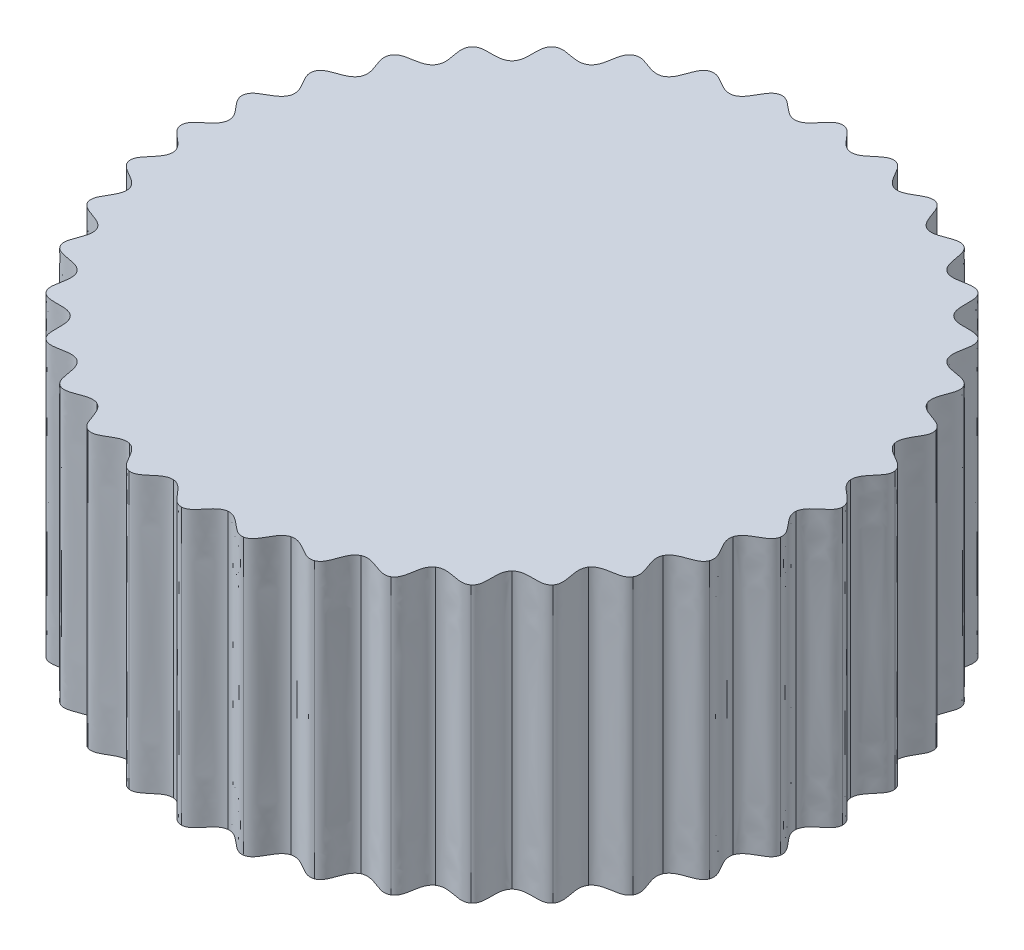
from build123d import *

# Parameters (mm, degrees)
BOSS_EXTRUDE1_DEPTH = 30


with BuildPart() as part:
    # Sketch1 → Boss-Extrude1 (new body)
    with BuildSketch(Plane(origin=(0, 0, 0), x_dir=(1, 0, 0), z_dir=(0, 1, 0))):
        with BuildLine():
            add(Edge.make_bspline(
                [(0, 36), (0.625233227, 36.007554002), (1.481885387, 34.899321986), (2.337586506, 33.935041496), (2.963295253, 33.870619735)],
                knots=[0, 0, 0, 0, 0.5, 1, 1, 1, 1], degree=3))
            add(Edge.make_bspline(
                [(6.251334396, 35.453079108), (5.636911605, 35.569088959), (4.600831447, 34.626449564), (3.590684801, 33.825409601), (2.963295253, 33.870619735)],
                knots=[0, 0, 0, 0, 0.5, 1, 1, 1, 1], degree=3))
            add(Edge.make_bspline(
                [(6.251334396, 35.453079108), (6.868380664, 35.351947738), (7.519575883, 34.11179617), (8.194831429, 33.013574328), (8.799847533, 32.841478094)],
                knots=[0, 0, 0, 0, 0.5, 1, 1, 1, 1], degree=3))
            add(Edge.make_bspline(
                [(12.31272516, 33.828934348), (11.727781731, 34.049875146), (10.543754345, 33.301469993), (9.409854966, 32.688009752), (8.799847533, 32.841478094)],
                knots=[0, 0, 0, 0, 0.5, 1, 1, 1, 1], degree=3))
            add(Edge.make_bspline(
                [(12.31272516, 33.828934348), (12.90283583, 33.62219043), (13.328787871, 32.287800688), (13.803080546, 31.089006408), (14.369020899, 30.814464759)],
                knots=[0, 0, 0, 0, 0.5, 1, 1, 1, 1], degree=3))
            add(Edge.make_bspline(
                [(18, 31.176914536), (17.462309143, 31.496073107), (16.166310602, 30.964642108), (14.943111451, 30.557401267), (14.369020899, 30.814464759)],
                knots=[0, 0, 0, 0, 0.5, 1, 1, 1, 1], degree=3))
            add(Edge.make_bspline(
                [(18, 31.176914536), (18.545244859, 30.87083988), (18.733011384, 29.482756721), (18.991930046, 28.219814761), (19.501598836, 27.851169506)],
                knots=[0, 0, 0, 0, 0.5, 1, 1, 1, 1], degree=3))
            add(Edge.make_bspline(
                [(23.140353949, 27.577599952), (22.666253128, 27.985278825), (21.297661693, 27.686969242), (20.022329055, 27.498321608), (19.501598836, 27.851169506)],
                knots=[0, 0, 0, 0, 0.5, 1, 1, 1, 1], degree=3))
            add(Edge.make_bspline(
                [(23.140353949, 27.577599952), (23.624166007, 27.181494482), (23.568041825, 25.78189411), (23.603719361, 24.493178323), (24.04163056, 24.04163056)],
                knots=[0, 0, 0, 0, 0.5, 1, 1, 1, 1], degree=3))
            add(Edge.make_bspline(
                [(27.577599952, 23.140353949), (27.181494482, 23.624166007), (25.78189411, 23.568041825), (24.493178323, 23.603719361), (24.04163056, 24.04163056)],
                knots=[0, 0, 0, 0, 0.5, 1, 1, 1, 1], degree=3))
            add(Edge.make_bspline(
                [(27.577599952, 23.140353949), (27.985278825, 22.666253128), (27.686969242, 21.297661693), (27.498321608, 20.022329055), (27.851169506, 19.501598836)],
                knots=[0, 0, 0, 0, 0.5, 1, 1, 1, 1], degree=3))
            add(Edge.make_bspline(
                [(31.176914536, 18), (30.87083988, 18.545244859), (29.482756721, 18.733011384), (28.219814761, 18.991930046), (27.851169506, 19.501598836)],
                knots=[0, 0, 0, 0, 0.5, 1, 1, 1, 1], degree=3))
            add(Edge.make_bspline(
                [(31.176914536, 18), (31.496073107, 17.462309143), (30.964642108, 16.166310602), (30.557401267, 14.943111451), (30.814464759, 14.369020899)],
                knots=[0, 0, 0, 0, 0.5, 1, 1, 1, 1], degree=3))
            add(Edge.make_bspline(
                [(33.828934348, 12.31272516), (33.62219043, 12.90283583), (32.287800688, 13.328787871), (31.089006408, 13.803080546), (30.814464759, 14.369020899)],
                knots=[0, 0, 0, 0, 0.5, 1, 1, 1, 1], degree=3))
            add(Edge.make_bspline(
                [(33.828934348, 12.31272516), (34.049875146, 11.727781731), (33.301469993, 10.543754345), (32.688009752, 9.409854966), (32.841478094, 8.799847533)],
                knots=[0, 0, 0, 0, 0.5, 1, 1, 1, 1], degree=3))
            add(Edge.make_bspline(
                [(35.453079108, 6.251334396), (35.351947738, 6.868380664), (34.11179617, 7.519575883), (33.013574328, 8.194831429), (32.841478094, 8.799847533)],
                knots=[0, 0, 0, 0, 0.5, 1, 1, 1, 1], degree=3))
            add(Edge.make_bspline(
                [(35.453079108, 6.251334396), (35.569088959, 5.636911605), (34.626449564, 4.600831447), (33.825409601, 3.590684801), (33.870619735, 2.963295253)],
                knots=[0, 0, 0, 0, 0.5, 1, 1, 1, 1], degree=3))
            add(Edge.make_bspline(
                [(36, 0), (36.007554002, 0.625233227), (34.899321986, 1.481885387), (33.935041496, 2.337586506), (33.870619735, 2.963295253)],
                knots=[0, 0, 0, 0, 0.5, 1, 1, 1, 1], degree=3))
            add(Edge.make_bspline(
                [(36, 0), (36.007554002, -0.625233227), (34.899321986, -1.481885387), (33.935041496, -2.337586506), (33.870619735, -2.963295253)],
                knots=[0, 0, 0, 0, 0.5, 1, 1, 1, 1], degree=3))
            add(Edge.make_bspline(
                [(35.453079108, -6.251334396), (35.569088959, -5.636911605), (34.626449564, -4.600831447), (33.825409601, -3.590684801), (33.870619735, -2.963295253)],
                knots=[0, 0, 0, 0, 0.5, 1, 1, 1, 1], degree=3))
            add(Edge.make_bspline(
                [(35.453079108, -6.251334396), (35.351947738, -6.868380664), (34.11179617, -7.519575883), (33.013574328, -8.194831429), (32.841478094, -8.799847533)],
                knots=[0, 0, 0, 0, 0.5, 1, 1, 1, 1], degree=3))
            add(Edge.make_bspline(
                [(33.828934348, -12.31272516), (34.049875146, -11.727781731), (33.301469993, -10.543754345), (32.688009752, -9.409854966), (32.841478094, -8.799847533)],
                knots=[0, 0, 0, 0, 0.5, 1, 1, 1, 1], degree=3))
            add(Edge.make_bspline(
                [(33.828934348, -12.31272516), (33.62219043, -12.90283583), (32.287800688, -13.328787871), (31.089006408, -13.803080546), (30.814464759, -14.369020899)],
                knots=[0, 0, 0, 0, 0.5, 1, 1, 1, 1], degree=3))
            add(Edge.make_bspline(
                [(31.176914536, -18), (31.496073107, -17.462309143), (30.964642108, -16.166310602), (30.557401267, -14.943111451), (30.814464759, -14.369020899)],
                knots=[0, 0, 0, 0, 0.5, 1, 1, 1, 1], degree=3))
            add(Edge.make_bspline(
                [(31.176914536, -18), (30.87083988, -18.545244859), (29.482756721, -18.733011384), (28.219814761, -18.991930046), (27.851169506, -19.501598836)],
                knots=[0, 0, 0, 0, 0.5, 1, 1, 1, 1], degree=3))
            add(Edge.make_bspline(
                [(27.577599952, -23.140353949), (27.985278825, -22.666253128), (27.686969242, -21.297661693), (27.498321608, -20.022329055), (27.851169506, -19.501598836)],
                knots=[0, 0, 0, 0, 0.5, 1, 1, 1, 1], degree=3))
            add(Edge.make_bspline(
                [(27.577599952, -23.140353949), (27.181494482, -23.624166007), (25.78189411, -23.568041825), (24.493178323, -23.603719361), (24.04163056, -24.04163056)],
                knots=[0, 0, 0, 0, 0.5, 1, 1, 1, 1], degree=3))
            add(Edge.make_bspline(
                [(23.140353949, -27.577599952), (23.624166007, -27.181494482), (23.568041825, -25.78189411), (23.603719361, -24.493178323), (24.04163056, -24.04163056)],
                knots=[0, 0, 0, 0, 0.5, 1, 1, 1, 1], degree=3))
            add(Edge.make_bspline(
                [(23.140353949, -27.577599952), (22.666253128, -27.985278825), (21.297661693, -27.686969242), (20.022329055, -27.498321608), (19.501598836, -27.851169506)],
                knots=[0, 0, 0, 0, 0.5, 1, 1, 1, 1], degree=3))
            add(Edge.make_bspline(
                [(18, -31.176914536), (18.545244859, -30.87083988), (18.733011384, -29.482756721), (18.991930046, -28.219814761), (19.501598836, -27.851169506)],
                knots=[0, 0, 0, 0, 0.5, 1, 1, 1, 1], degree=3))
            add(Edge.make_bspline(
                [(18, -31.176914536), (17.462309143, -31.496073107), (16.166310602, -30.964642108), (14.943111451, -30.557401267), (14.369020899, -30.814464759)],
                knots=[0, 0, 0, 0, 0.5, 1, 1, 1, 1], degree=3))
            add(Edge.make_bspline(
                [(12.31272516, -33.828934348), (12.90283583, -33.62219043), (13.328787871, -32.287800688), (13.803080546, -31.089006408), (14.369020899, -30.814464759)],
                knots=[0, 0, 0, 0, 0.5, 1, 1, 1, 1], degree=3))
            add(Edge.make_bspline(
                [(12.31272516, -33.828934348), (11.727781731, -34.049875146), (10.543754345, -33.301469993), (9.409854966, -32.688009752), (8.799847533, -32.841478094)],
                knots=[0, 0, 0, 0, 0.5, 1, 1, 1, 1], degree=3))
            add(Edge.make_bspline(
                [(6.251334396, -35.453079108), (6.868380664, -35.351947738), (7.519575883, -34.11179617), (8.194831429, -33.013574328), (8.799847533, -32.841478094)],
                knots=[0, 0, 0, 0, 0.5, 1, 1, 1, 1], degree=3))
            add(Edge.make_bspline(
                [(6.251334396, -35.453079108), (5.636911605, -35.569088959), (4.600831447, -34.626449564), (3.590684801, -33.825409601), (2.963295253, -33.870619735)],
                knots=[0, 0, 0, 0, 0.5, 1, 1, 1, 1], degree=3))
            add(Edge.make_bspline(
                [(0, -36), (0.625233227, -36.007554002), (1.481885387, -34.899321986), (2.337586506, -33.935041496), (2.963295253, -33.870619735)],
                knots=[0, 0, 0, 0, 0.5, 1, 1, 1, 1], degree=3))
            add(Edge.make_bspline(
                [(0, -36), (-0.625233227, -36.007554002), (-1.481885387, -34.899321986), (-2.337586506, -33.935041496), (-2.963295253, -33.870619735)],
                knots=[0, 0, 0, 0, 0.5, 1, 1, 1, 1], degree=3))
            add(Edge.make_bspline(
                [(-6.251334396, -35.453079108), (-5.636911605, -35.569088959), (-4.600831447, -34.626449564), (-3.590684801, -33.825409601), (-2.963295253, -33.870619735)],
                knots=[0, 0, 0, 0, 0.5, 1, 1, 1, 1], degree=3))
            add(Edge.make_bspline(
                [(-6.251334396, -35.453079108), (-6.868380664, -35.351947738), (-7.519575883, -34.11179617), (-8.194831429, -33.013574328), (-8.799847533, -32.841478094)],
                knots=[0, 0, 0, 0, 0.5, 1, 1, 1, 1], degree=3))
            add(Edge.make_bspline(
                [(-12.31272516, -33.828934348), (-11.727781731, -34.049875146), (-10.543754345, -33.301469993), (-9.409854966, -32.688009752), (-8.799847533, -32.841478094)],
                knots=[0, 0, 0, 0, 0.5, 1, 1, 1, 1], degree=3))
            add(Edge.make_bspline(
                [(-12.31272516, -33.828934348), (-12.90283583, -33.62219043), (-13.328787871, -32.287800688), (-13.803080546, -31.089006408), (-14.369020899, -30.814464759)],
                knots=[0, 0, 0, 0, 0.5, 1, 1, 1, 1], degree=3))
            add(Edge.make_bspline(
                [(-18, -31.176914536), (-17.462309143, -31.496073107), (-16.166310602, -30.964642108), (-14.943111451, -30.557401267), (-14.369020899, -30.814464759)],
                knots=[0, 0, 0, 0, 0.5, 1, 1, 1, 1], degree=3))
            add(Edge.make_bspline(
                [(-18, -31.176914536), (-18.545244859, -30.87083988), (-18.733011384, -29.482756721), (-18.991930046, -28.219814761), (-19.501598836, -27.851169506)],
                knots=[0, 0, 0, 0, 0.5, 1, 1, 1, 1], degree=3))
            add(Edge.make_bspline(
                [(-23.140353949, -27.577599952), (-22.666253128, -27.985278825), (-21.297661693, -27.686969242), (-20.022329055, -27.498321608), (-19.501598836, -27.851169506)],
                knots=[0, 0, 0, 0, 0.5, 1, 1, 1, 1], degree=3))
            add(Edge.make_bspline(
                [(-23.140353949, -27.577599952), (-23.624166007, -27.181494482), (-23.568041825, -25.78189411), (-23.603719361, -24.493178323), (-24.04163056, -24.04163056)],
                knots=[0, 0, 0, 0, 0.5, 1, 1, 1, 1], degree=3))
            add(Edge.make_bspline(
                [(-27.577599952, -23.140353949), (-27.181494482, -23.624166007), (-25.78189411, -23.568041825), (-24.493178323, -23.603719361), (-24.04163056, -24.04163056)],
                knots=[0, 0, 0, 0, 0.5, 1, 1, 1, 1], degree=3))
            add(Edge.make_bspline(
                [(-27.577599952, -23.140353949), (-27.985278825, -22.666253128), (-27.686969242, -21.297661693), (-27.498321608, -20.022329055), (-27.851169506, -19.501598836)],
                knots=[0, 0, 0, 0, 0.5, 1, 1, 1, 1], degree=3))
            add(Edge.make_bspline(
                [(-31.176914536, -18), (-30.87083988, -18.545244859), (-29.482756721, -18.733011384), (-28.219814761, -18.991930046), (-27.851169506, -19.501598836)],
                knots=[0, 0, 0, 0, 0.5, 1, 1, 1, 1], degree=3))
            add(Edge.make_bspline(
                [(-31.176914536, -18), (-31.496073107, -17.462309143), (-30.964642108, -16.166310602), (-30.557401267, -14.943111451), (-30.814464759, -14.369020899)],
                knots=[0, 0, 0, 0, 0.5, 1, 1, 1, 1], degree=3))
            add(Edge.make_bspline(
                [(-33.828934348, -12.31272516), (-33.62219043, -12.90283583), (-32.287800688, -13.328787871), (-31.089006408, -13.803080546), (-30.814464759, -14.369020899)],
                knots=[0, 0, 0, 0, 0.5, 1, 1, 1, 1], degree=3))
            add(Edge.make_bspline(
                [(-33.828934348, -12.31272516), (-34.049875146, -11.727781731), (-33.301469993, -10.543754345), (-32.688009752, -9.409854966), (-32.841478094, -8.799847533)],
                knots=[0, 0, 0, 0, 0.5, 1, 1, 1, 1], degree=3))
            add(Edge.make_bspline(
                [(-35.453079108, -6.251334396), (-35.351947738, -6.868380664), (-34.11179617, -7.519575883), (-33.013574328, -8.194831429), (-32.841478094, -8.799847533)],
                knots=[0, 0, 0, 0, 0.5, 1, 1, 1, 1], degree=3))
            add(Edge.make_bspline(
                [(-35.453079108, -6.251334396), (-35.569088959, -5.636911605), (-34.626449564, -4.600831447), (-33.825409601, -3.590684801), (-33.870619735, -2.963295253)],
                knots=[0, 0, 0, 0, 0.5, 1, 1, 1, 1], degree=3))
            add(Edge.make_bspline(
                [(-36, 0), (-36.007554002, -0.625233227), (-34.899321986, -1.481885387), (-33.935041496, -2.337586506), (-33.870619735, -2.963295253)],
                knots=[0, 0, 0, 0, 0.5, 1, 1, 1, 1], degree=3))
            add(Edge.make_bspline(
                [(-36, 0), (-36.007554002, 0.625233227), (-34.899321986, 1.481885387), (-33.935041496, 2.337586506), (-33.870619735, 2.963295253)],
                knots=[0, 0, 0, 0, 0.5, 1, 1, 1, 1], degree=3))
            add(Edge.make_bspline(
                [(-35.453079108, 6.251334396), (-35.569088959, 5.636911605), (-34.626449564, 4.600831447), (-33.825409601, 3.590684801), (-33.870619735, 2.963295253)],
                knots=[0, 0, 0, 0, 0.5, 1, 1, 1, 1], degree=3))
            add(Edge.make_bspline(
                [(-35.453079108, 6.251334396), (-35.351947738, 6.868380664), (-34.11179617, 7.519575883), (-33.013574328, 8.194831429), (-32.841478094, 8.799847533)],
                knots=[0, 0, 0, 0, 0.5, 1, 1, 1, 1], degree=3))
            add(Edge.make_bspline(
                [(-33.828934348, 12.31272516), (-34.049875146, 11.727781731), (-33.301469993, 10.543754345), (-32.688009752, 9.409854966), (-32.841478094, 8.799847533)],
                knots=[0, 0, 0, 0, 0.5, 1, 1, 1, 1], degree=3))
            add(Edge.make_bspline(
                [(-33.828934348, 12.31272516), (-33.62219043, 12.90283583), (-32.287800688, 13.328787871), (-31.089006408, 13.803080546), (-30.814464759, 14.369020899)],
                knots=[0, 0, 0, 0, 0.5, 1, 1, 1, 1], degree=3))
            add(Edge.make_bspline(
                [(-31.176914536, 18), (-31.496073107, 17.462309143), (-30.964642108, 16.166310602), (-30.557401267, 14.943111451), (-30.814464759, 14.369020899)],
                knots=[0, 0, 0, 0, 0.5, 1, 1, 1, 1], degree=3))
            add(Edge.make_bspline(
                [(-31.176914536, 18), (-30.87083988, 18.545244859), (-29.482756721, 18.733011384), (-28.219814761, 18.991930046), (-27.851169506, 19.501598836)],
                knots=[0, 0, 0, 0, 0.5, 1, 1, 1, 1], degree=3))
            add(Edge.make_bspline(
                [(-27.577599952, 23.140353949), (-27.985278825, 22.666253128), (-27.686969242, 21.297661693), (-27.498321608, 20.022329055), (-27.851169506, 19.501598836)],
                knots=[0, 0, 0, 0, 0.5, 1, 1, 1, 1], degree=3))
            add(Edge.make_bspline(
                [(-27.577599952, 23.140353949), (-27.181494482, 23.624166007), (-25.78189411, 23.568041825), (-24.493178323, 23.603719361), (-24.04163056, 24.04163056)],
                knots=[0, 0, 0, 0, 0.5, 1, 1, 1, 1], degree=3))
            add(Edge.make_bspline(
                [(-23.140353949, 27.577599952), (-23.624166007, 27.181494482), (-23.568041825, 25.78189411), (-23.603719361, 24.493178323), (-24.04163056, 24.04163056)],
                knots=[0, 0, 0, 0, 0.5, 1, 1, 1, 1], degree=3))
            add(Edge.make_bspline(
                [(-23.140353949, 27.577599952), (-22.666253128, 27.985278825), (-21.297661693, 27.686969242), (-20.022329055, 27.498321608), (-19.501598836, 27.851169506)],
                knots=[0, 0, 0, 0, 0.5, 1, 1, 1, 1], degree=3))
            add(Edge.make_bspline(
                [(-18, 31.176914536), (-18.545244859, 30.87083988), (-18.733011384, 29.482756721), (-18.991930046, 28.219814761), (-19.501598836, 27.851169506)],
                knots=[0, 0, 0, 0, 0.5, 1, 1, 1, 1], degree=3))
            add(Edge.make_bspline(
                [(-18, 31.176914536), (-17.462309143, 31.496073107), (-16.166310602, 30.964642108), (-14.943111451, 30.557401267), (-14.369020899, 30.814464759)],
                knots=[0, 0, 0, 0, 0.5, 1, 1, 1, 1], degree=3))
            add(Edge.make_bspline(
                [(-12.31272516, 33.828934348), (-12.90283583, 33.62219043), (-13.328787871, 32.287800688), (-13.803080546, 31.089006408), (-14.369020899, 30.814464759)],
                knots=[0, 0, 0, 0, 0.5, 1, 1, 1, 1], degree=3))
            add(Edge.make_bspline(
                [(-12.31272516, 33.828934348), (-11.727781731, 34.049875146), (-10.543754345, 33.301469993), (-9.409854966, 32.688009752), (-8.799847533, 32.841478094)],
                knots=[0, 0, 0, 0, 0.5, 1, 1, 1, 1], degree=3))
            add(Edge.make_bspline(
                [(-6.251334396, 35.453079108), (-6.868380664, 35.351947738), (-7.519575883, 34.11179617), (-8.194831429, 33.013574328), (-8.799847533, 32.841478094)],
                knots=[0, 0, 0, 0, 0.5, 1, 1, 1, 1], degree=3))
            add(Edge.make_bspline(
                [(-6.251334396, 35.453079108), (-5.636911605, 35.569088959), (-4.600831447, 34.626449564), (-3.590684801, 33.825409601), (-2.963295253, 33.870619735)],
                knots=[0, 0, 0, 0, 0.5, 1, 1, 1, 1], degree=3))
            add(Edge.make_bspline(
                [(0, 36), (-0.625233227, 36.007554002), (-1.481885387, 34.899321986), (-2.337586506, 33.935041496), (-2.963295253, 33.870619735)],
                knots=[0, 0, 0, 0, 0.5, 1, 1, 1, 1], degree=3))
        make_face()
    extrude(amount=BOSS_EXTRUDE1_DEPTH)


solid = part.part
